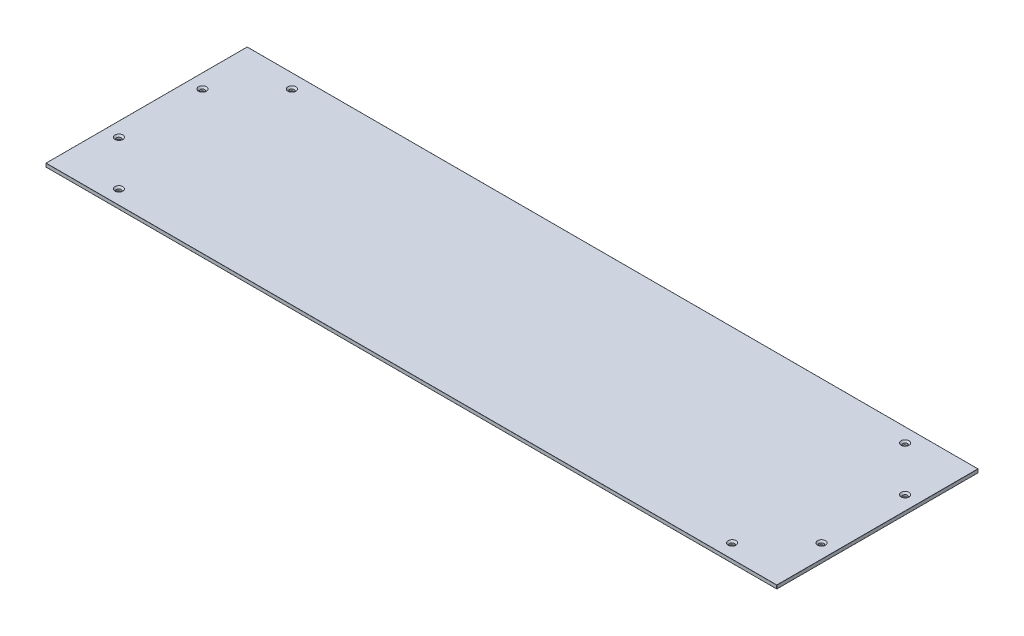
from build123d import *

# Parameters (mm, degrees)
SKETCH1_W           = 1242
SKETCH1_H           = 342
BOSS_EXTRUDE1_DEPTH = 6
SKETCH2_R           = 4
CUT_EXTRUDE1_DEPTH  = 7
CHAMFER1_SIZE       = 2.75
FILLET1_R           = 0.2


with BuildPart() as part:
    # Sketch1 → Boss-Extrude1 (new body)
    with BuildSketch(Plane(origin=(0, 0, 0), x_dir=(1, 0, 0), z_dir=(0, 1, 0))):
        Rectangle(SKETCH1_W, SKETCH1_H)
    extrude(amount=BOSS_EXTRUDE1_DEPTH)

    # Sketch2 → Cut-Extrude1 (cut, through all)
    with BuildSketch(Plane(origin=(0, 6, 0), x_dir=(1, 0, 0), z_dir=(0, 1, 0))):
        with Locations((-521, -147)):
            Circle(SKETCH2_R)
        with Locations((521, -147)):
            Circle(SKETCH2_R)
        with Locations((-597, -71)):
            Circle(SKETCH2_R)
        with Locations((597, -71)):
            Circle(SKETCH2_R)
        with Locations((597, 71)):
            Circle(SKETCH2_R)
        with Locations((521, 147)):
            Circle(SKETCH2_R)
        with Locations((-521, 147)):
            Circle(SKETCH2_R)
        with Locations((-597, 71)):
            Circle(SKETCH2_R)
    extrude(amount=-CUT_EXTRUDE1_DEPTH, mode=Mode.SUBTRACT)

    # Chamfer1
    chamfer1_edges = [part.edges().sort_by_distance(p)[0] for p in [
        (-525, 6, 147),
        (517, 6, 147),
        (-601, 6, 71),
        (593, 6, 71),
        (593, 6, -71),
        (517, 6, -147),
        (-525, 6, -147),
        (-601, 6, -71),
    ]]
    chamfer(chamfer1_edges, length=CHAMFER1_SIZE)

    # Fillet1
    fillet1_edges = [part.edges().sort_by_distance(p)[0] for p in [
        (-621, 6, 0),
        (0, 6, 171),
        (621, 6, 0),
        (0, 0, 171),
        (-621, 0, 0),
        (0, 0, -171),
        (621, 0, 0),
        (0, 6, -171),
        (621, 3, 171),
        (-621, 3, 171),
        (-621, 3, -171),
        (621, 3, -171),
    ]]
    fillet(fillet1_edges, radius=FILLET1_R)


solid = part.part
